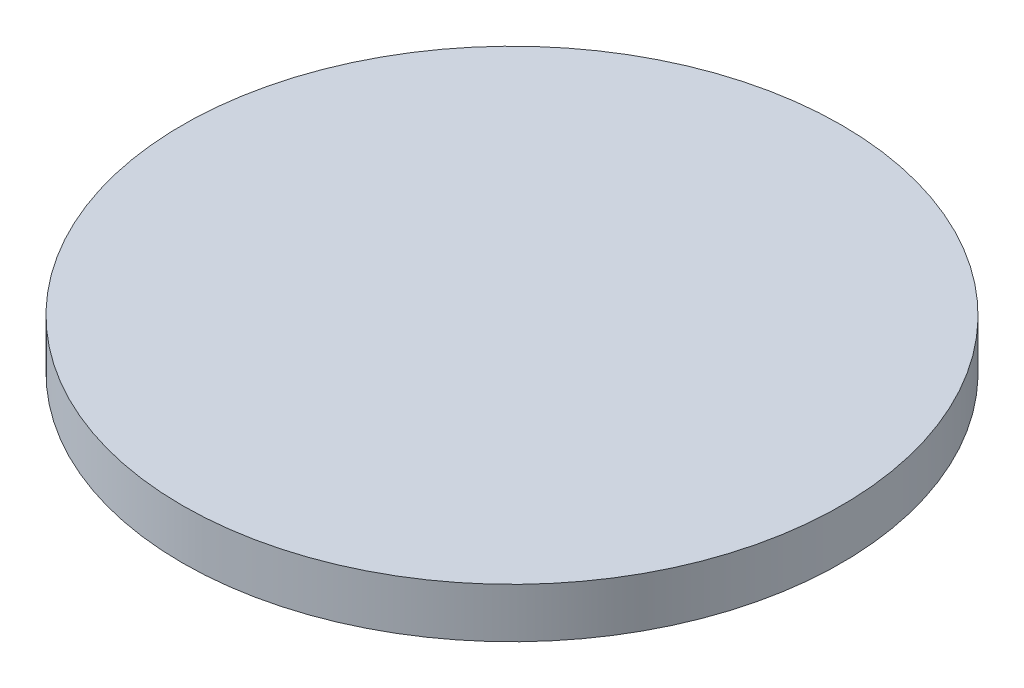
from build123d import *

# Parameters (mm, degrees)
SKETCH1_R           = 5.3
BOSS_EXTRUDE1_DEPTH = 0.8


with BuildPart() as part:
    # Sketch1 → Boss-Extrude1 (new body)
    with BuildSketch(Plane(origin=(0, 0, 0), x_dir=(1, 0, 0), z_dir=(0, 1, 0))):
        Circle(SKETCH1_R)
    extrude(amount=BOSS_EXTRUDE1_DEPTH)


solid = part.part
